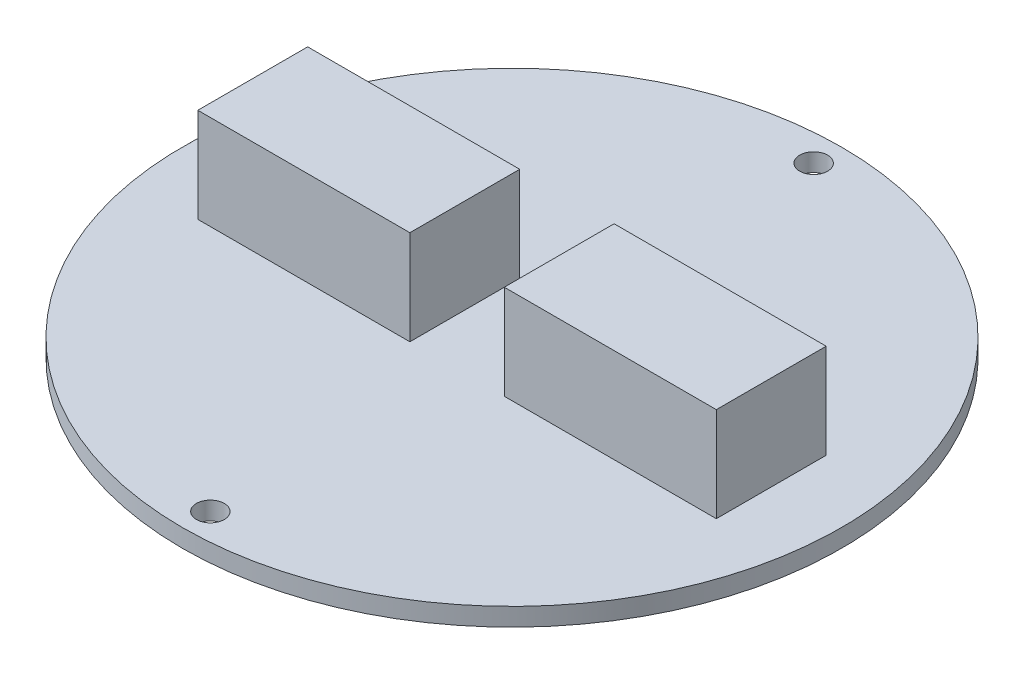
from build123d import *

# Parameters (mm, degrees)
SKETCH1_R           = 30
BOSS_EXTRUDE1_DEPTH = 1.64
SKETCH2_R           = 1.27
CUT_EXTRUDE1_DEPTH  = 2.64
SKETCH3_W           = 19.304
SKETCH3_H           = 10
BOSS_EXTRUDE2_DEPTH = 8.6


with BuildPart() as part:
    # Sketch1 → Boss-Extrude1 (new body)
    with BuildSketch(Plane(origin=(0, 0, 0), x_dir=(1, 0, 0), z_dir=(0, 1, 0))):
        Circle(SKETCH1_R)
    extrude(amount=BOSS_EXTRUDE1_DEPTH)

    # Sketch2 → Cut-Extrude1 (cut, through all)
    with BuildSketch(Plane(origin=(0, 1.64, 0), x_dir=(1, 0, 0), z_dir=(0, 1, 0))):
        with Locations((0, 27.46)):
            Circle(SKETCH2_R)
        with Locations((0, -27.46)):
            Circle(SKETCH2_R)
    extrude(amount=-CUT_EXTRUDE1_DEPTH, mode=Mode.SUBTRACT)

    # Sketch3 → Boss-Extrude2 (add)
    with BuildSketch(Plane(origin=(0, 1.64, 0), x_dir=(1, 0, 0), z_dir=(0, 1, 0))):
        with Locations((-13.948, 0)):
            Rectangle(SKETCH3_W, SKETCH3_H)
        with Locations((13.948, 0)):
            Rectangle(SKETCH3_W, SKETCH3_H)
    extrude(amount=BOSS_EXTRUDE2_DEPTH)


solid = part.part
